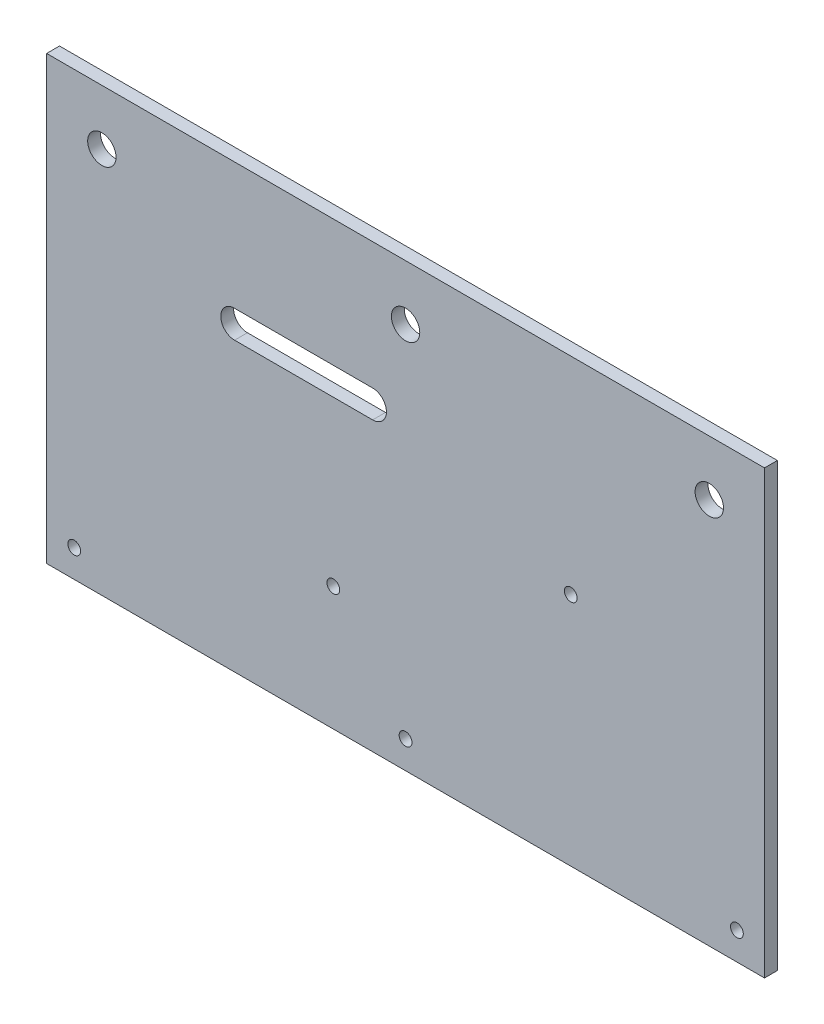
from build123d import *

# Parameters (mm, degrees)
SKETCH1_W               = 165.1
SKETCH1_H               = 101.6
BOSS_EXTRUDE1_DEPTH     = 1.47955
F_1_4_CLEARANCE_HOLE1_D = 6.5278
F_4_CLEARANCE_HOLE1_D   = 2.9464


with BuildPart() as part:
    # Sketch1 → Boss-Extrude1 (new body, symmetric)
    with BuildSketch(Plane.XY):
        Rectangle(SKETCH1_W, SKETCH1_H)
        with BuildLine():
            ThreePointArc((-7.575, 15.3), (-4.4, 18.475), (-7.575, 21.65))
            Line((-7.575, 21.65), (-39.325, 21.65))
            ThreePointArc((-39.325, 21.65), (-42.5, 18.475), (-39.325, 15.3))
            Line((-39.325, 15.3), (-7.575, 15.3))
        make_face(mode=Mode.SUBTRACT)
    extrude(amount=BOSS_EXTRUDE1_DEPTH, both=True)

    # 1/4 Clearance Hole1 (through all)
    with Locations(Plane(origin=(-54.280585756, -28.309576901, 1.47955), x_dir=(1, 0, 0), z_dir=(0, 0, 1))):
        with Locations((-15.569414244, 66.409576901), (124.130585756, 66.409576901), (54.280585756, 66.409576901)):
            Hole(F_1_4_CLEARANCE_HOLE1_D / 2)

    # #4 Clearance Hole1 (through all)
    with Locations(Plane(origin=(-67.931660522, 13.630291587, 1.47955), x_dir=(1, 0, 0), z_dir=(0, 0, 1))):
        with Locations((105.931660522, -10.330291587), (51.321660522, -35.984291587), (-8.268339478, -58.080291587), (144.131660522, -58.080291587), (67.931660522, -58.080291587)):
            Hole(F_4_CLEARANCE_HOLE1_D / 2)


solid = part.part
